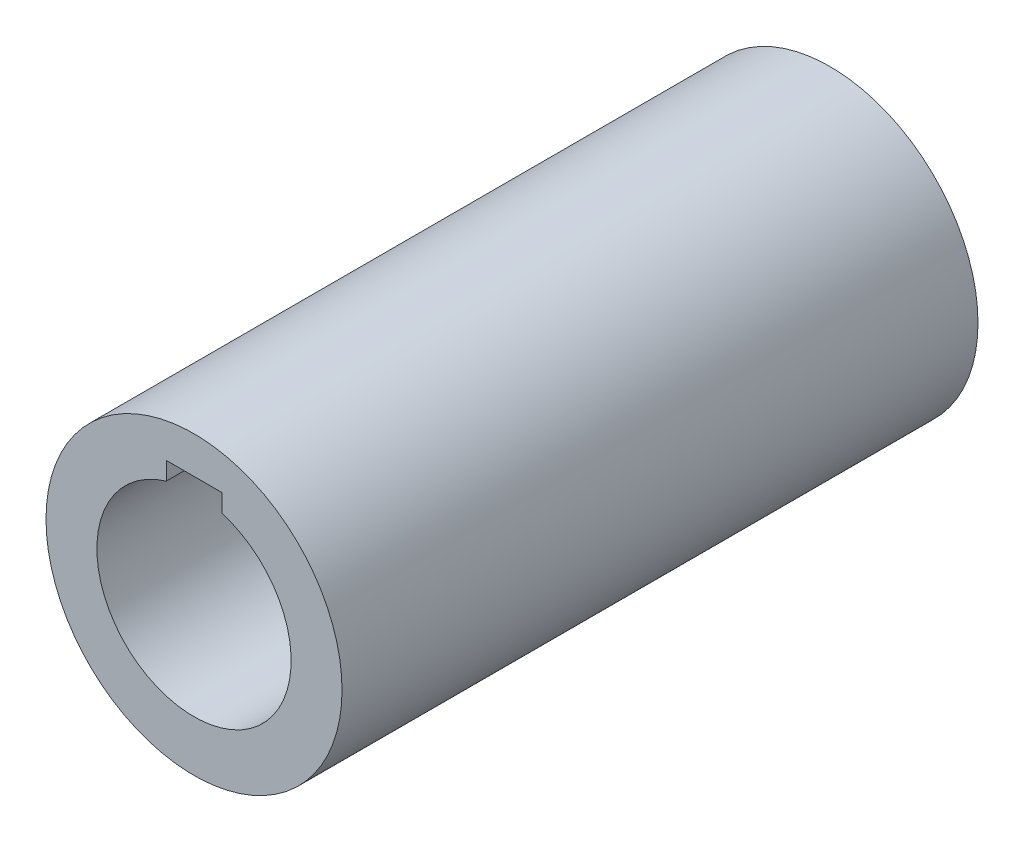
from build123d import *

# Parameters (mm, degrees)
SKETCH1_R           = 32
SKETCH1_R_2         = 21
BOSS_EXTRUDE1_DEPTH = 137.5
SKETCH2_W           = 12
SKETCH2_H           = 3.875388203
CUT_EXTRUDE1_DEPTH  = 138.5


with BuildPart() as part:
    # Sketch1 → Boss-Extrude1 (new body)
    with BuildSketch(Plane.XY):
        Circle(SKETCH1_R)
        Circle(SKETCH1_R_2, mode=Mode.SUBTRACT)
    extrude(amount=BOSS_EXTRUDE1_DEPTH)

    # Sketch2 → Cut-Extrude1 (cut, through all)
    with BuildSketch(Plane.XY.offset(137.5)):
        with Locations((0, 22.062305899)):
            Rectangle(SKETCH2_W, SKETCH2_H)
    extrude(amount=-CUT_EXTRUDE1_DEPTH, mode=Mode.SUBTRACT)


solid = part.part
